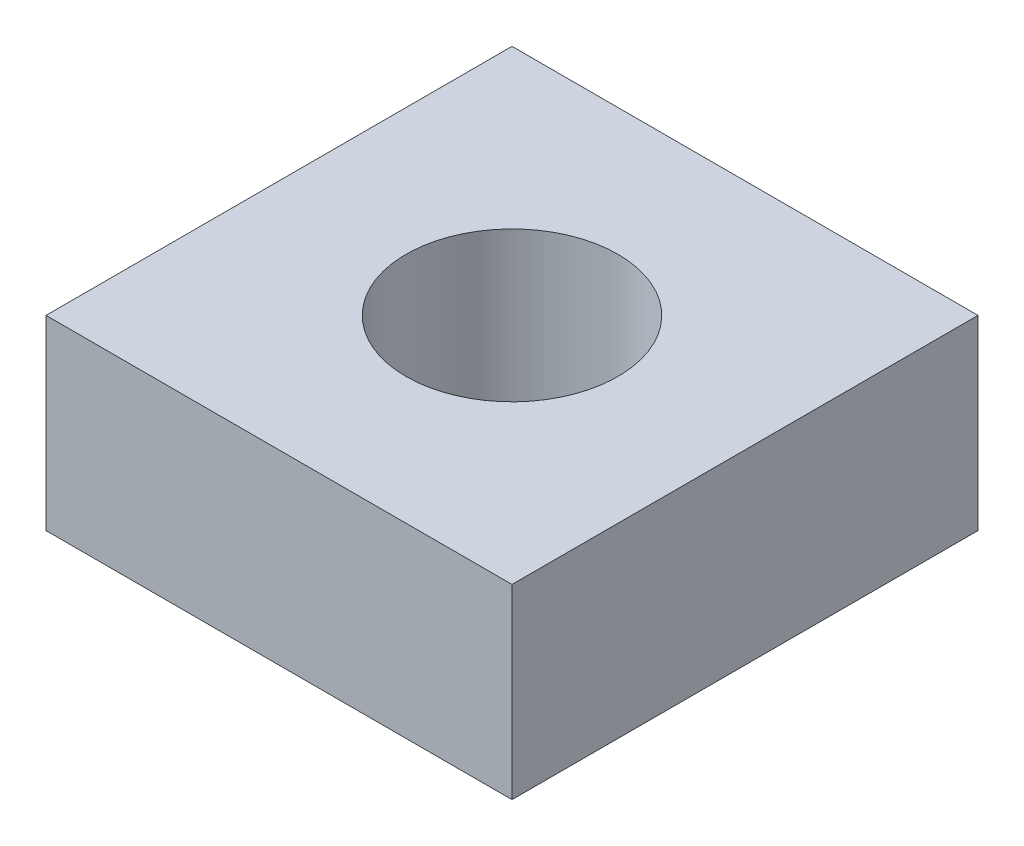
from build123d import *

# Parameters (mm, degrees)
SKETCH1_W             = 5.5
SKETCH1_H             = 5.5
BOSS_EXTRUDE1_DEPTH   = 2.2
M3X0_5_TAPPED_HOLE1_D = 2.5


with BuildPart() as part:
    # Sketch1 → Boss-Extrude1 (new body)
    with BuildSketch(Plane(origin=(0, 0, 0), x_dir=(1, 0, 0), z_dir=(0, 1, 0))):
        Rectangle(SKETCH1_W, SKETCH1_H)
    extrude(amount=BOSS_EXTRUDE1_DEPTH)

    # M3x0.5 Tapped Hole1 (through all)
    with Locations(Plane(origin=(0, 2.2, 0), x_dir=(1, 0, 0), z_dir=(0, 1, 0))):
        with Locations((0, 0)):
            Hole(M3X0_5_TAPPED_HOLE1_D / 2)


solid = part.part
